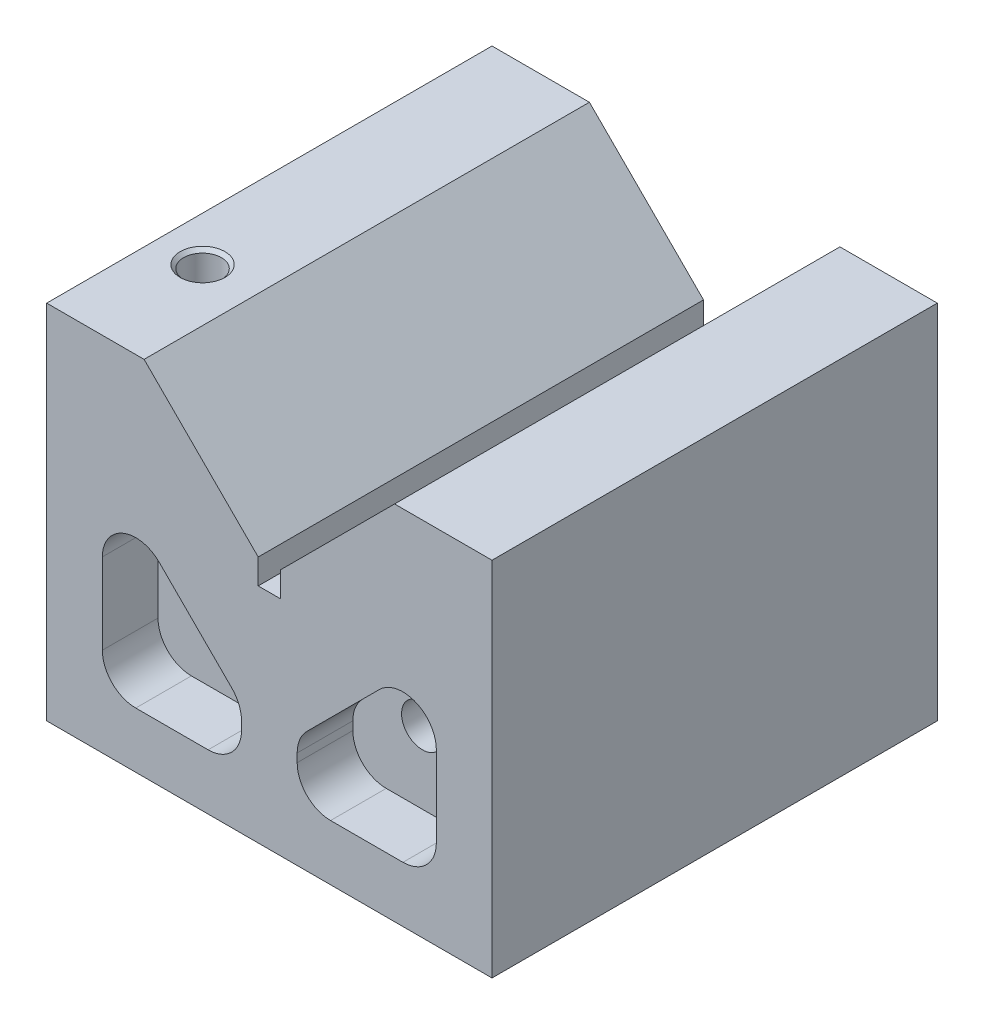
from build123d import *

# Parameters (mm, degrees)
Y_KSEKLIK_EKSTR_ZYON1_DEPTH = 40
IZIM2_R                     = 3.75
KES_EKSTR_ZYON1_DEPTH       = 10
IZIM3_R                     = 3.75
KES_EKSTR_ZYON2_DEPTH       = 81
M8_DI_LI_DELIK1_D           = 6.8
M8_DI_LI_DELIK1_DEPTH       = 18
M8_DI_LI_DELIK1_CSINK_D     = 8.05
M8_DI_LI_DELIK1_CSINK_ANGLE = 90
M8_DI_LI_DELIK1_TIP         = 2.042926105


with BuildPart() as part:
    # Çizim1 → Yükseklik-Ekstrüzyon1 (new body, symmetric)
    with BuildSketch(Plane.XY):
        Polygon((2, 0), (-2, 0), (-2, 4.5), (-22.5, 25), (-40, 25), (-40, -40), (40, -40), (40, 25), (22.5, 25), (2, 4.5), align=None)
    extrude(amount=Y_KSEKLIK_EKSTR_ZYON1_DEPTH, both=True)

    # Çizim2 → Kes-Ekstrüzyon1 (cut)
    with BuildSketch(Plane.XY.offset(40)):
        with BuildLine():
            Line((30, -9.485281374), (30, -24))
            ThreePointArc((30, -24), (28.242640687, -28.242640687), (24, -30))
            Line((24, -30), (11, -30))
            ThreePointArc((11, -30), (6.757359313, -28.242640687), (5, -24))
            Line((5, -24), (5, -22.485281374))
            ThreePointArc((5, -22.485281374), (5.456722805, -20.18918078), (6.757359313, -18.242640687))
            Line((6.757359313, -18.242640687), (19.757359313, -5.242640687))
            ThreePointArc((19.757359313, -5.242640687), (26.296100594, -3.942004179), (30, -9.485281374))
        make_face()
        with Locations((17.5, -17)):
            Circle(IZIM2_R, mode=Mode.SUBTRACT)
        with BuildLine():
            Line((-24, -30), (-11, -30))
            ThreePointArc((-11, -30), (-6.757359313, -28.242640687), (-5, -24))
            Line((-5, -24), (-5, -22.485281374))
            ThreePointArc((-5, -22.485281374), (-5.456722805, -20.18918078), (-6.757359313, -18.242640687))
            Line((-6.757359313, -18.242640687), (-19.757359313, -5.242640687))
            ThreePointArc((-19.757359313, -5.242640687), (-26.296100594, -3.942004179), (-30, -9.485281374))
            Line((-30, -9.485281374), (-30, -24))
            ThreePointArc((-30, -24), (-28.242640687, -28.242640687), (-24, -30))
        make_face()
        with Locations((-17.5, -17)):
            Circle(IZIM2_R, mode=Mode.SUBTRACT)
    kes_ekstr_zyon1 = extrude(amount=-KES_EKSTR_ZYON1_DEPTH, mode=Mode.SUBTRACT)

    # Aynalama1: Kes-Ekstrüzyon1 across plane
    add(kes_ekstr_zyon1.mirror(Plane.XY), mode=Mode.SUBTRACT)

    # Çizim3 → Kes-Ekstrüzyon2 (cut, through all)
    with BuildSketch(Plane.XY.offset(40)):
        with Locations((-17.5, -17)):
            Circle(IZIM3_R)
        with Locations((17.5, -17)):
            Circle(IZIM3_R)
    extrude(amount=-KES_EKSTR_ZYON2_DEPTH, mode=Mode.SUBTRACT)

    # M8 Dişli Delik1
    with Locations(Plane(origin=(0, 25, 0), x_dir=(1, 0, 0), z_dir=(0, 1, 0))):
        with Locations((-32, -20)):
            CounterSinkHole(M8_DI_LI_DELIK1_D / 2, M8_DI_LI_DELIK1_CSINK_D / 2, depth=M8_DI_LI_DELIK1_DEPTH, counter_sink_angle=M8_DI_LI_DELIK1_CSINK_ANGLE)
            with Locations((0, 0, -(M8_DI_LI_DELIK1_DEPTH + M8_DI_LI_DELIK1_TIP / 2))):  # 118° drill point
                Cone(0, M8_DI_LI_DELIK1_D / 2, M8_DI_LI_DELIK1_TIP, mode=Mode.SUBTRACT)


solid = part.part
